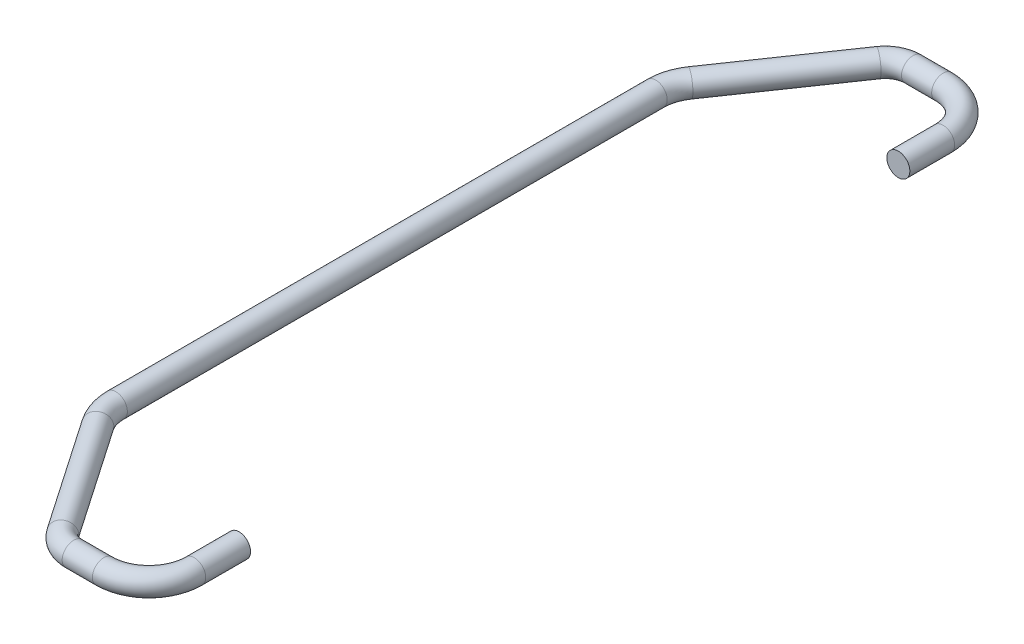
from build123d import *

# Parameters (mm, degrees)
SKETCH3_R = 3.175


with BuildPart() as part:
    # Sweep1: sweep along a path in Sketch2
    with BuildLine(Plane(origin=(0, 0, 0), x_dir=(1, 0, 0), z_dir=(0, 1, 0))) as sweep1_path:
        Line((-42.005520706, 0), (-42.005520706, 74.510370248))
        ThreePointArc((-42.005520706, 74.510370248), (-41.43579821, 78.271535981), (-39.777746269, 81.695249631))
        Line((-39.777746269, 81.695249631), (-18.645117879, 112.496831598))
        ThreePointArc((-18.645117879, 112.496831598), (-15.912495952, 114.928072333), (-12.361782541, 115.805903968))
        Line((-12.361782541, 115.805903968), (-4.027166859, 115.805903968))
        ThreePointArc((-4.027166859, 115.805903968), (4.766000348, 112.163654854), (8.408249461, 103.370487647))
        Line((8.408249461, 103.370487647), (8.408249461, 90.998440491))
    # Sketch3 → Sweep1 (sweep)
    with BuildSketch(Plane.XY):
        with Locations((-42.04385452, 0)):
            Circle(SKETCH3_R)
    sweep1 = sweep(path=sweep1_path.line)

    # Mirror2: Sweep1 across plane
    add(sweep1.mirror(Plane(origin=(-42.04385452, 0, 0), x_dir=(1, 0, 0), z_dir=(0, 0, 1))))


solid = part.part
